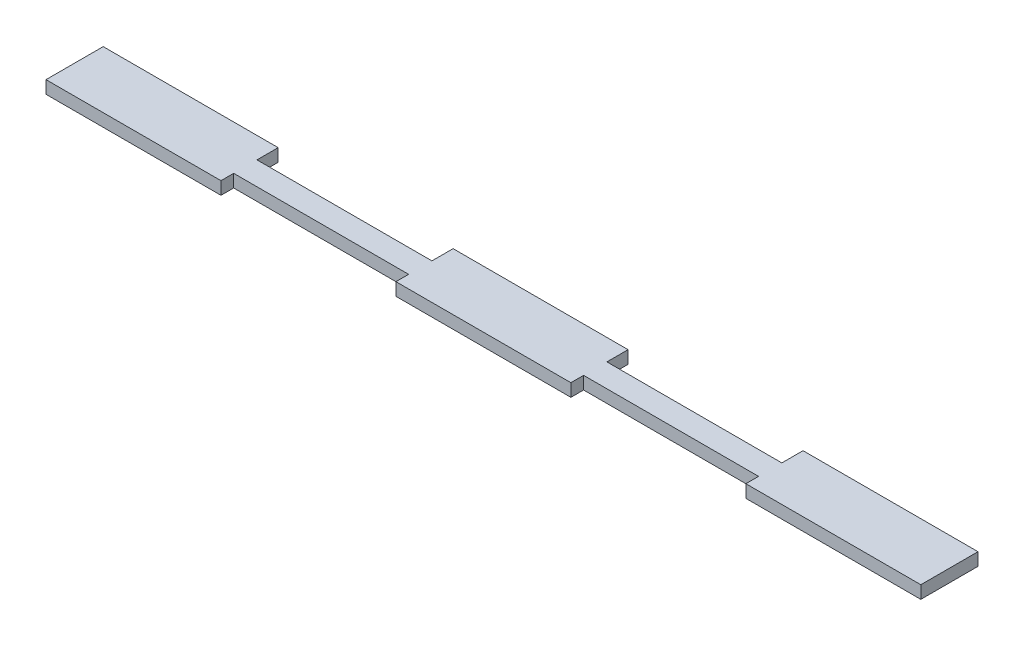
from build123d import *

# Parameters (mm, degrees)
BOSS_EXTRUDE1_DEPTH = 3


with BuildPart() as part:
    # Sketch1 → Boss-Extrude1 (new body)
    with BuildSketch(Plane(origin=(0, 0, 0), x_dir=(1, 0, 0), z_dir=(0, 1, 0))):
        Polygon((-103.25, 6.75), (-61.95, 6.75), (-61.95, 1.75), (-20.65, 1.75), (-20.65, 6.75), (20.65, 6.75), (20.65, 1.75), (61.95, 1.75), (61.95, 6.75), (103.25, 6.75), (103.25, -6.75), (61.95, -6.75), (61.95, -3.75), (20.65, -3.75), (20.65, -6.75), (-20.65, -6.75), (-20.65, -3.75), (-61.95, -3.75), (-61.95, -6.75), (-103.25, -6.75), align=None)
    extrude(amount=BOSS_EXTRUDE1_DEPTH)


solid = part.part
